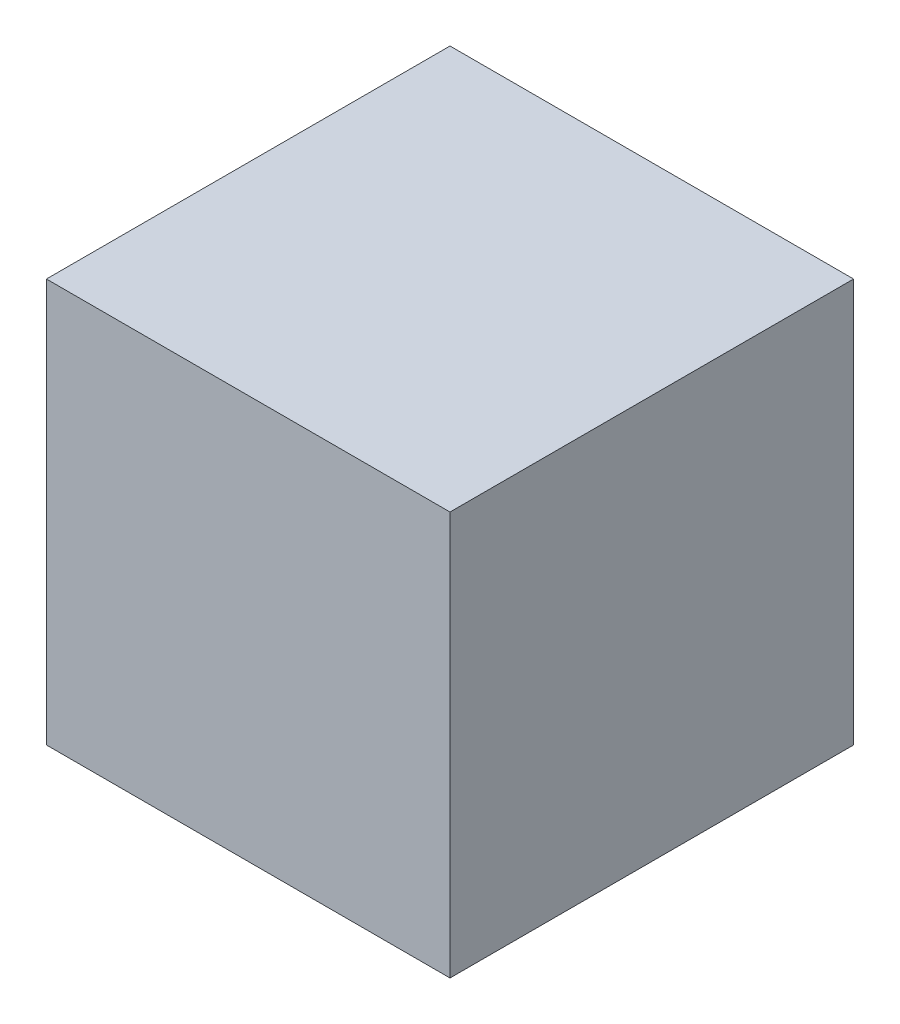
from build123d import *

# Parameters (mm, degrees)
SKETCH1_W           = 10
SKETCH1_H           = 10
BOSS_EXTRUDE2_DEPTH = 10


with BuildPart() as part:
    # Sketch1 → Boss-Extrude2 (new body)
    with BuildSketch(Plane(origin=(0, 0, 0), x_dir=(1, 0, 0), z_dir=(0, 1, 0))):
        with Locations((-5, 5)):
            Rectangle(SKETCH1_W, SKETCH1_H)
    extrude(amount=BOSS_EXTRUDE2_DEPTH)


solid = part.part
